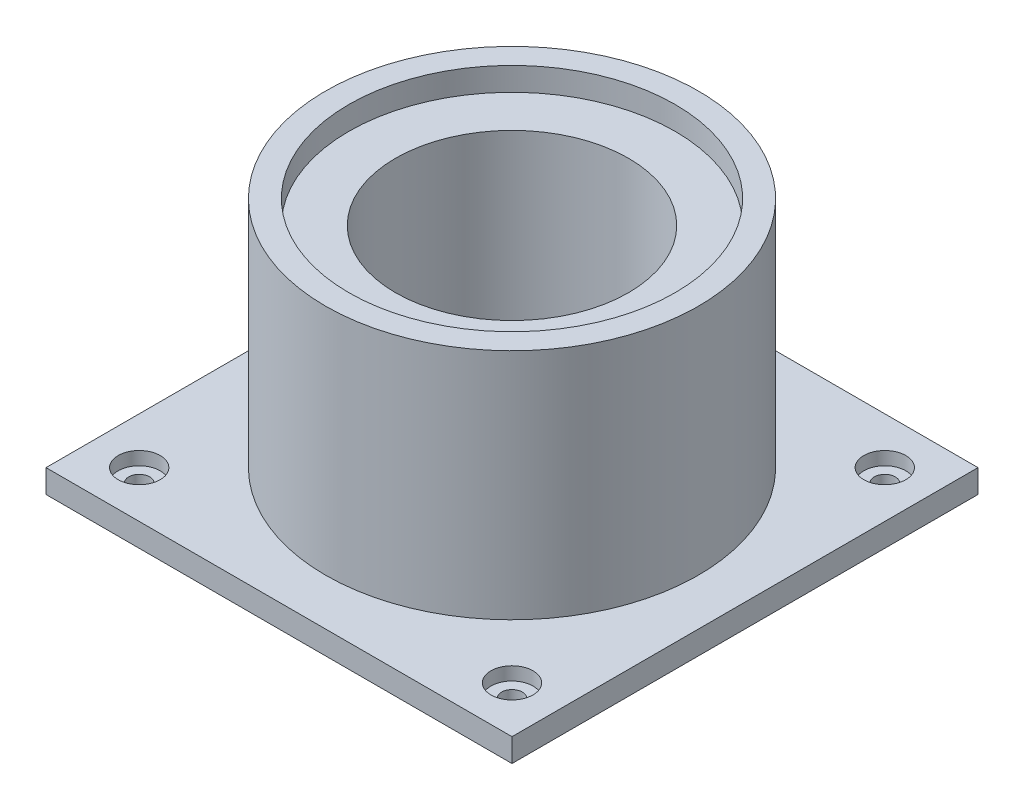
from build123d import *

# Parameters (mm, degrees)
SKETCH1_W                               = 200
SKETCH1_H                               = 200
BOSS_EXTRUDE1_DEPTH                     = 10
SKETCH2_R                               = 80
BOSS_EXTRUDE2_DEPTH                     = 100
SKETCH3_R                               = 50
CUT_EXTRUDE1_DEPTH                      = 100
SKETCH4_R                               = 70
CUT_EXTRUDE2_DEPTH                      = 10
CBORE_FOR_M8_HEX_HEAD_BOLT1_D           = 9
CBORE_FOR_M8_HEX_HEAD_BOLT1_CBORE_D     = 18.01
CBORE_FOR_M8_HEX_HEAD_BOLT1_CBORE_DEPTH = 5.68


with BuildPart() as part:
    # Sketch1 → Boss-Extrude1 (new body)
    with BuildSketch(Plane(origin=(0, 0, 0), x_dir=(1, 0, 0), z_dir=(0, 1, 0))):
        Rectangle(SKETCH1_W, SKETCH1_H)
    extrude(amount=BOSS_EXTRUDE1_DEPTH)

    # Sketch2 → Boss-Extrude2 (add)
    with BuildSketch(Plane(origin=(0, 10, 0), x_dir=(1, 0, 0), z_dir=(0, 1, 0))):
        Circle(SKETCH2_R)
    extrude(amount=BOSS_EXTRUDE2_DEPTH)

    # Sketch3 → Cut-Extrude1 (cut)
    with BuildSketch(Plane(origin=(0, 110, 0), x_dir=(1, 0, 0), z_dir=(0, 1, 0))):
        Circle(SKETCH3_R)
    extrude(amount=-CUT_EXTRUDE1_DEPTH, mode=Mode.SUBTRACT)

    # Sketch4 → Cut-Extrude2 (cut)
    with BuildSketch(Plane(origin=(0, 110, 0), x_dir=(1, 0, 0), z_dir=(0, 1, 0))):
        Circle(SKETCH4_R)
    extrude(amount=-CUT_EXTRUDE2_DEPTH, mode=Mode.SUBTRACT)

    # CBORE for M8 Hex Head Bolt1 (through all)
    with Locations(Plane(origin=(80, 10, -80), x_dir=(0, 0, 1), z_dir=(0, 1, 0))):
        with Locations((0, 0), (0, -160), (160, 0), (160, -160)):
            CounterBoreHole(CBORE_FOR_M8_HEX_HEAD_BOLT1_D / 2, CBORE_FOR_M8_HEX_HEAD_BOLT1_CBORE_D / 2, CBORE_FOR_M8_HEX_HEAD_BOLT1_CBORE_DEPTH)


solid = part.part
